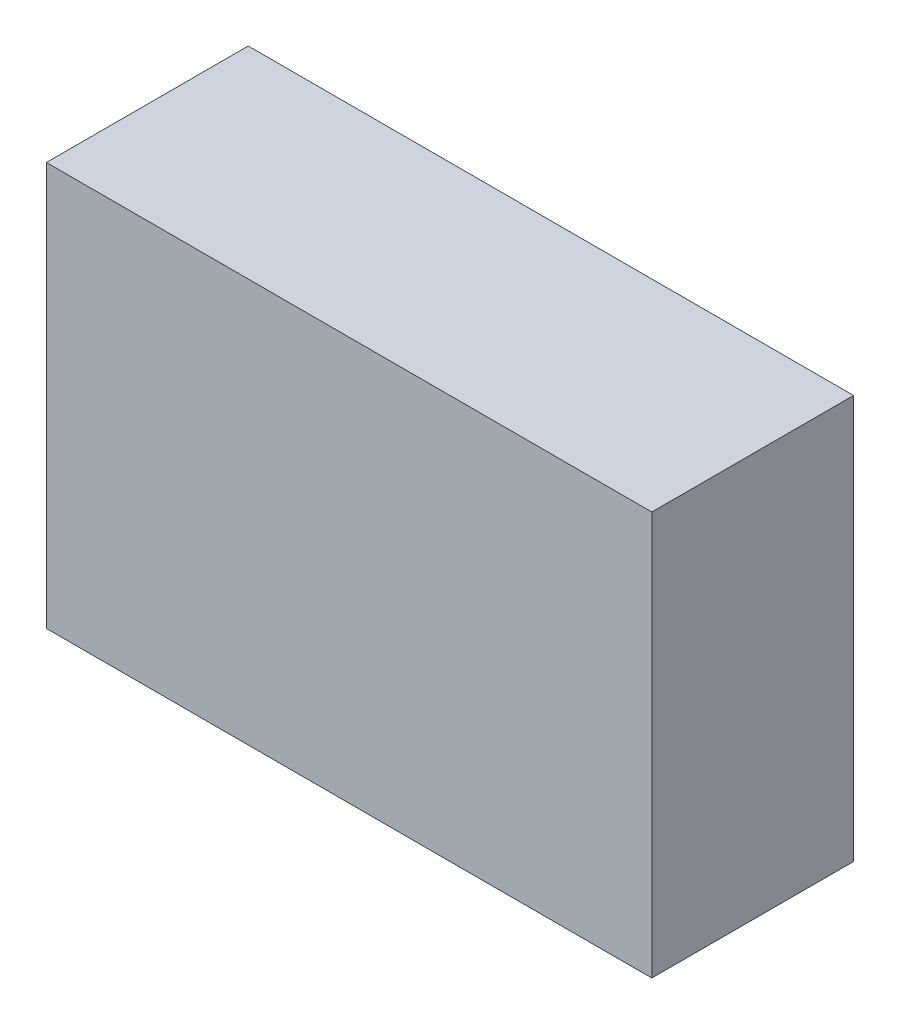
from build123d import *

# Parameters (mm, degrees)
SKETCH1_W      = 300
SKETCH1_H      = 200
EXTRUDE1_DEPTH = 100


with BuildPart() as part:
    # Sketch1 → Extrude1 (new body)
    with BuildSketch(Plane.XY):
        Rectangle(SKETCH1_W, SKETCH1_H)
    extrude(amount=EXTRUDE1_DEPTH)


solid = part.part
